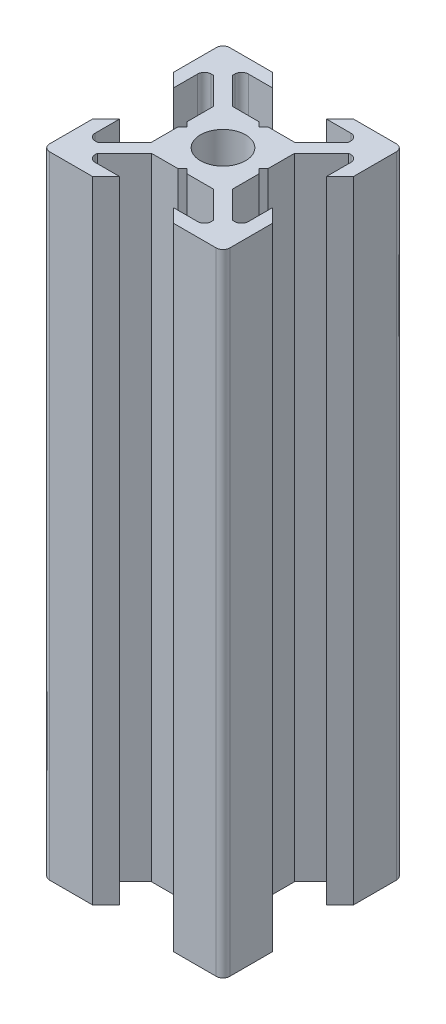
from build123d import *

# Parameters (mm, degrees)
ESQUISSE1_R      = 2.5
EXTRUSION1_DEPTH = 70
CONG_1_R         = 0.75


with BuildPart() as part:
    # Esquisse1 → Extrusion1 (new body)
    with BuildSketch(Plane(origin=(0, 0, 0), x_dir=(1, 0, 0), z_dir=(0, 1, 0))):
        Polygon((0, 4), (-0.5, 4.5), (-3.439339828, 4.5), (-6.439339828, 7.5), (-6.439339828, 8.5), (-3, 8.5), (-4.5, 10), (-10, 10), (-10, 4.5), (-8.5, 3), (-8.5, 6.439339828), (-7.5, 6.439339828), (-4.5, 3.439339828), (-4.5, 0.5), (-4, 0), (-4.5, -0.5), (-4.5, -3.439339828), (-7.5, -6.439339828), (-8.5, -6.439339828), (-8.5, -3), (-10, -4.5), (-10, -10), (-4.5, -10), (-3, -8.5), (-6.439339828, -8.5), (-6.439339828, -7.5), (-3.439339828, -4.5), (-0.5, -4.5), (0, -4), (0.5, -4.5), (3.439339828, -4.5), (6.439339828, -7.5), (6.439339828, -8.5), (3, -8.5), (4.5, -10), (10, -10), (10, -4.5), (8.5, -3), (8.5, -6.439339828), (7.5, -6.439339828), (4.5, -3.439339828), (4.5, -0.5), (4, 0), (4.5, 0.5), (4.5, 3.439339828), (7.5, 6.439339828), (8.5, 6.439339828), (8.5, 3), (10, 4.5), (10, 10), (4.5, 10), (3, 8.5), (6.439339828, 8.5), (6.439339828, 7.5), (3.439339828, 4.5), (0.5, 4.5), align=None)
        Circle(ESQUISSE1_R, mode=Mode.SUBTRACT)
    extrude(amount=EXTRUSION1_DEPTH)

    # Congé1
    cong_1_edges = [part.edges().sort_by_distance(p)[0] for p in [
        (6.439339828, 35, -8.5),
        (10, 35, -10),
        (8.5, 35, -6.439339828),
        (8.5, 35, 6.439339828),
        (10, 35, 10),
        (6.439339828, 35, 8.5),
        (-6.439339828, 35, 8.5),
        (-10, 35, 10),
        (-8.5, 35, 6.439339828),
        (-8.5, 35, -6.439339828),
        (-10, 35, -10),
        (-6.439339828, 35, -8.5),
    ]]
    fillet(cong_1_edges, radius=CONG_1_R)


solid = part.part
